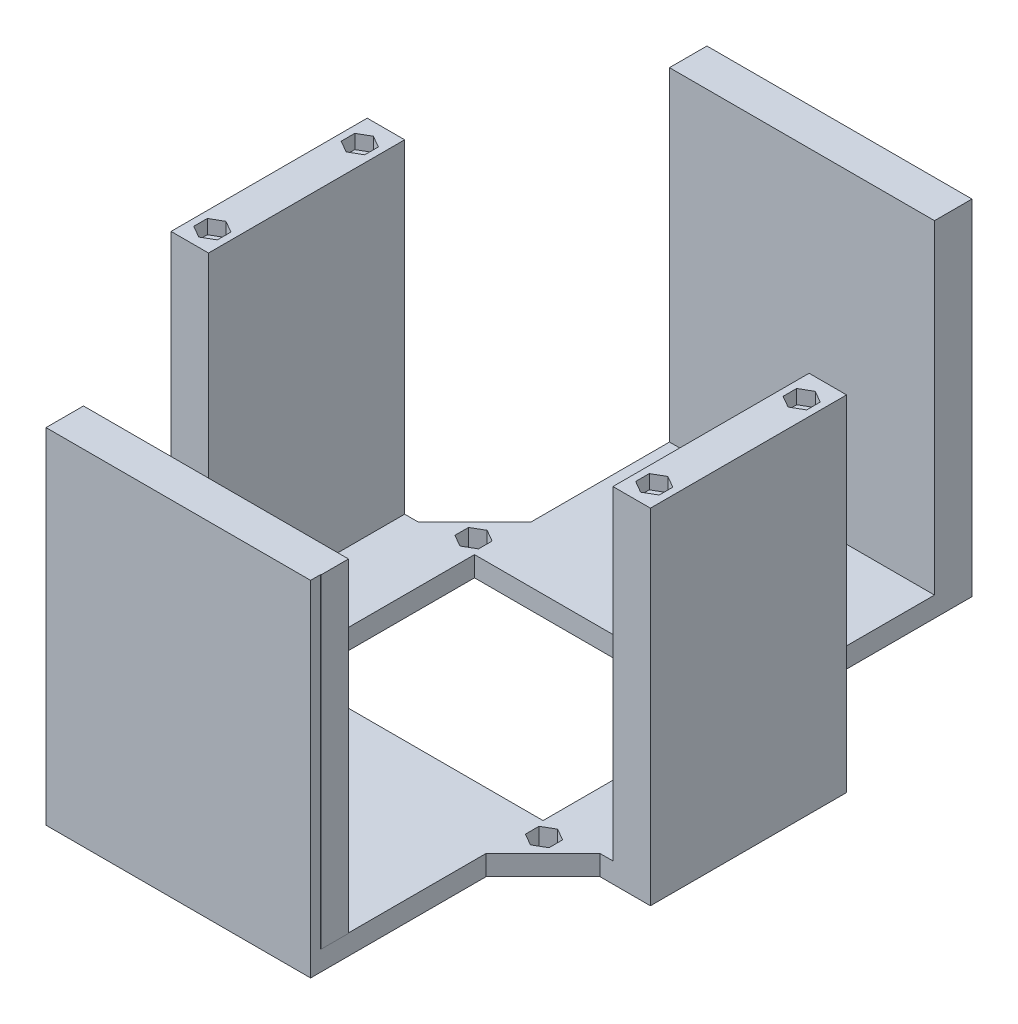
from build123d import *

# Parameters (mm, degrees)
BOSS_EXTRUDE1_DEPTH   = 20
BOSS_EXTRUDE1_2_DEPTH = 20
BOSS_EXTRUDE1_3_DEPTH = 20
BOSS_EXTRUDE1_4_DEPTH = 20
SKETCH6_W             = 12
SKETCH6_H             = 5
BOSS_EXTRUDE5_DEPTH   = 65.8
SKETCH7_W             = 12
SKETCH7_H             = 5
BOSS_EXTRUDE6_DEPTH   = 48.7
SKETCH8_W             = 12.175
SKETCH8_H             = 5
BOSS_EXTRUDE7_DEPTH   = 12.16
SKETCH9_W             = 12.175
SKETCH9_H             = 5
BOSS_EXTRUDE8_DEPTH   = 12.16
SKETCH11_W            = 6.8
SKETCH11_H            = 12.175
BOSS_EXTRUDE9_DEPTH   = 80.5
SKETCH14_W            = 12.175
SKETCH14_H            = 5
BOSS_EXTRUDE12_DEPTH  = 43.2
SKETCH15_W            = 12.175
SKETCH15_H            = 5
BOSS_EXTRUDE13_DEPTH  = 43.2
SKETCH16_W            = 12.175
SKETCH16_H            = 6.8
BOSS_EXTRUDE14_DEPTH  = 80.5
SKETCH17_W            = 16.970562748
SKETCH17_H            = 15
CUT_EXTRUDE1_DEPTH    = 10
SKETCH18_W            = 16.970562748
SKETCH18_H            = 15
CUT_EXTRUDE2_DEPTH    = 10
SKETCH19_W            = 16.970562748
SKETCH19_H            = 15
CUT_EXTRUDE3_DEPTH    = 10
SKETCH20_W            = 16.970562748
SKETCH20_H            = 15
CUT_EXTRUDE4_DEPTH    = 10
BOSS_EXTRUDE15_DEPTH  = 50
BOSS_EXTRUDE16_DEPTH  = 30
SKETCH26_W            = 16.970562748
SKETCH26_H            = 5
BOSS_EXTRUDE17_DEPTH  = 1.5
SKETCH27_W            = 1.5
SKETCH27_H            = 5
BOSS_EXTRUDE18_DEPTH  = 2.5
SKETCH28_W            = 1.5
SKETCH28_H            = 5
BOSS_EXTRUDE20_DEPTH  = 2.5
SKETCH29_W            = 16.810915376
SKETCH29_H            = 5
BOSS_EXTRUDE21_DEPTH  = 1.5
SKETCH30_W            = 1.5
SKETCH30_H            = 5
BOSS_EXTRUDE22_DEPTH  = 3.5
SKETCH31_W            = 1.5
SKETCH31_H            = 5
BOSS_EXTRUDE23_DEPTH  = 3.5
SKETCH32_W            = 16.781669725
SKETCH32_H            = 5
BOSS_EXTRUDE24_DEPTH  = 1.5
SKETCH33_W            = 1.5
SKETCH33_H            = 5
BOSS_EXTRUDE25_DEPTH  = 2.5
SKETCH34_W            = 1.5
SKETCH34_H            = 5
BOSS_EXTRUDE26_DEPTH  = 2.5
SKETCH35_W            = 16.941317097
SKETCH35_H            = 5
BOSS_EXTRUDE27_DEPTH  = 1.5
SKETCH36_W            = 1.5
SKETCH36_H            = 5
BOSS_EXTRUDE28_DEPTH  = 2.5
SKETCH38_W            = 1.5
SKETCH38_H            = 5
BOSS_EXTRUDE29_DEPTH  = 2.5
SKETCH43_W            = 48.7
SKETCH43_H            = 85.5
BOSS_EXTRUDE30_DEPTH  = 2.5
SKETCH44_W            = 48.7
SKETCH44_H            = 85.5
BOSS_EXTRUDE31_DEPTH  = 2.5
SKETCH45_W            = 65.68711226
SKETCH45_H            = 85.5
BOSS_EXTRUDE32_DEPTH  = 2.5
SKETCH46_W            = 65.8
SKETCH46_H            = 85.5
BOSS_EXTRUDE33_DEPTH  = 2.5
CUT_EXTRUDE5_DEPTH    = 3.5


with BuildPart() as part:
    # Sketch2 → Boss-Extrude1 (new body)
    with BuildSketch(Plane(origin=(0, 0, 0), x_dir=(1, 0, 0), z_dir=(0, 1, 0))):
        Polygon((-32.84355613, 36.339660101), (-32.84355613, 24.339660101), (-44.84355613, 24.339660101), align=None)
        Polygon((-33.575, 29.438749537), (-33.575, 26.061250463), (-36.5, 24.372500925), (-39.425, 26.061250463), (-39.425, 29.438749537), (-36.5, 31.127499075), align=None, mode=Mode.SUBTRACT)
    extrude(amount=BOSS_EXTRUDE1_DEPTH)



with BuildPart() as body_2:
    # Sketch2 → Boss-Extrude1 2 (new body)
    with BuildSketch(Plane(origin=(0, 0, 0), x_dir=(1, 0, 0), z_dir=(0, 1, 0))):
        Polygon((32.84355613, 24.339660101), (44.84355613, 24.339660101), (32.84355613, 36.339660101), align=None)
        Polygon((33.575, 29.438749537), (33.575, 26.061250463), (36.5, 24.372500925), (39.425, 26.061250463), (39.425, 29.438749537), (36.5, 31.127499075), align=None, mode=Mode.SUBTRACT)
    extrude(amount=BOSS_EXTRUDE1_2_DEPTH)


with BuildPart() as body_3:
    # Sketch2 → Boss-Extrude1 3 (new body)
    with BuildSketch(Plane(origin=(0, 0, 0), x_dir=(1, 0, 0), z_dir=(0, 1, 0))):
        Polygon((44.84355613, -24.339660101), (32.84355613, -36.339660101), (32.84355613, -24.339660101), align=None)
        Polygon((39.425, -26.061250463), (39.425, -29.438749537), (36.5, -31.127499075), (33.575, -29.438749537), (33.575, -26.061250463), (36.5, -24.372500925), align=None, mode=Mode.SUBTRACT)
    extrude(amount=BOSS_EXTRUDE1_3_DEPTH)


with BuildPart() as body_4:
    # Sketch2 → Boss-Extrude1 4 (new body)
    with BuildSketch(Plane(origin=(0, 0, 0), x_dir=(1, 0, 0), z_dir=(0, 1, 0))):
        Polygon((-44.84355613, -24.339660101), (-32.84355613, -36.339660101), (-32.84355613, -24.339660101), align=None)
        Polygon((-36.5, -31.127499075), (-33.575, -29.438749537), (-33.575, -26.061250463), (-36.5, -24.372500925), (-39.425, -26.061250463), (-39.425, -29.438749537), align=None, mode=Mode.SUBTRACT)
    extrude(amount=BOSS_EXTRUDE1_4_DEPTH)


with BuildPart() as part_1:
    add(part.part)

    add(body_2.part)  # Boss-Extrude5 merges body 2

    add(body_3.part)  # Boss-Extrude5 merges body 3

    add(body_4.part)  # Boss-Extrude5 merges body 4
    # Sketch6 → Boss-Extrude5 (add)
    with BuildSketch(Plane(origin=(-32.84355613, 0, 0), x_dir=(0, 0, -1), z_dir=(1, 0, 0))):
        with Locations((30.339660101, 17.5)):
            Rectangle(SKETCH6_W, SKETCH6_H)
        with Locations((-30.339660101, 17.5)):
            Rectangle(SKETCH6_W, SKETCH6_H)
    extrude(amount=BOSS_EXTRUDE5_DEPTH)

    # Sketch7 → Boss-Extrude6 (add)
    with BuildSketch(Plane(origin=(0, 0, 24.339660101), x_dir=(-1, 0, 0), z_dir=(0, 0, -1))):
        with Locations((-38.84355613, 17.5)):
            Rectangle(SKETCH7_W, SKETCH7_H)
        with Locations((38.84355613, 17.5)):
            Rectangle(SKETCH7_W, SKETCH7_H)
    extrude(amount=BOSS_EXTRUDE6_DEPTH)

    # Sketch8 → Boss-Extrude7 (add)
    with BuildSketch(Plane(origin=(44.84355613, 0, 0), x_dir=(0, 0, -1), z_dir=(1, 0, 0))):
        with Locations((-18.252160101, 17.5)):
            Rectangle(SKETCH8_W, SKETCH8_H)
        with Locations((18.272839899, 17.5)):
            Rectangle(SKETCH8_W, SKETCH8_H)
    extrude(amount=BOSS_EXTRUDE7_DEPTH)

    # Sketch9 → Boss-Extrude8 (add)
    with BuildSketch(Plane.ZY.offset(44.84355613)):
        with Locations((-18.272839899, 17.5)):
            Rectangle(SKETCH9_W, SKETCH9_H)
        with Locations((18.252160101, 17.5)):
            Rectangle(SKETCH9_W, SKETCH9_H)
    extrude(amount=BOSS_EXTRUDE8_DEPTH)

    # Sketch11 → Boss-Extrude9 (add)
    with BuildSketch(Plane(origin=(0, 20, 0), x_dir=(1, 0, 0), z_dir=(0, 1, 0))):
        with Locations((-53.60355613, -18.252160101)):
            Rectangle(SKETCH11_W, SKETCH11_H)
        with Locations((-53.60355613, 18.272839899)):
            Rectangle(SKETCH11_W, SKETCH11_H)
        with Locations((53.60355613, 18.272839899)):
            Rectangle(SKETCH11_W, SKETCH11_H)
        with Locations((53.60355613, -18.252160101)):
            Rectangle(SKETCH11_W, SKETCH11_H)
    extrude(amount=BOSS_EXTRUDE9_DEPTH)

    # Sketch14 → Boss-Extrude12 (add)
    with BuildSketch(Plane.XY.offset(36.339660101)):
        with Locations((-26.75605613, 17.5)):
            Rectangle(SKETCH14_W, SKETCH14_H)
        with Locations((26.75605613, 17.5)):
            Rectangle(SKETCH14_W, SKETCH14_H)
    extrude(amount=BOSS_EXTRUDE12_DEPTH)

    # Sketch15 → Boss-Extrude13 (add)
    with BuildSketch(Plane(origin=(0, 0, -36.339660101), x_dir=(-1, 0, 0), z_dir=(0, 0, -1))):
        with Locations((-26.86894387, 17.5)):
            Rectangle(SKETCH15_W, SKETCH15_H)
        with Locations((26.75605613, 17.5)):
            Rectangle(SKETCH15_W, SKETCH15_H)
    extrude(amount=BOSS_EXTRUDE13_DEPTH)

    # Sketch16 → Boss-Extrude14 (add)
    with BuildSketch(Plane(origin=(0, 20, 0), x_dir=(1, 0, 0), z_dir=(0, 1, 0))):
        with Locations((-26.75605613, 76.139660101)):
            Rectangle(SKETCH16_W, SKETCH16_H)
        with Locations((26.86894387, 76.139660101)):
            Rectangle(SKETCH16_W, SKETCH16_H)
        with Locations((26.86894387, -76.139660101)):
            Rectangle(SKETCH16_W, SKETCH16_H)
        with Locations((-26.75605613, -76.139660101)):
            Rectangle(SKETCH16_W, SKETCH16_H)
    extrude(amount=BOSS_EXTRUDE14_DEPTH)

    # Sketch17 → Cut-Extrude1 (cut)
    with BuildSketch(Plane(origin=(34.591608116, 0, -34.591608116), x_dir=(-0.707106781, 0, -0.707106781), z_dir=(0.707106781, 0, -0.707106781))):
        with Locations((-6.013162549, 7.5)):
            Rectangle(SKETCH17_W, SKETCH17_H)
    extrude(amount=-CUT_EXTRUDE1_DEPTH, mode=Mode.SUBTRACT)

    # Sketch18 → Cut-Extrude2 (cut)
    with BuildSketch(Plane(origin=(-34.591608116, 0, -34.591608116), x_dir=(-0.707106781, 0, 0.707106781), z_dir=(-0.707106781, 0, -0.707106781))):
        with Locations((6.013162549, 7.5)):
            Rectangle(SKETCH18_W, SKETCH18_H)
    extrude(amount=-CUT_EXTRUDE2_DEPTH, mode=Mode.SUBTRACT)

    # Sketch19 → Cut-Extrude3 (cut)
    with BuildSketch(Plane(origin=(-34.591608116, 0, 34.591608116), x_dir=(0.707106781, 0, 0.707106781), z_dir=(-0.707106781, 0, 0.707106781))):
        with Locations((-6.013162549, 7.5)):
            Rectangle(SKETCH19_W, SKETCH19_H)
    extrude(amount=-CUT_EXTRUDE3_DEPTH, mode=Mode.SUBTRACT)

    # Sketch20 → Cut-Extrude4 (cut)
    with BuildSketch(Plane(origin=(34.591608116, 0, 34.591608116), x_dir=(0.707106781, 0, -0.707106781), z_dir=(0.707106781, 0, 0.707106781))):
        with Locations((6.013162549, 7.5)):
            Rectangle(SKETCH20_W, SKETCH20_H)
    extrude(amount=-CUT_EXTRUDE4_DEPTH, mode=Mode.SUBTRACT)

    # Sketch21 → Boss-Extrude15 (add)
    with BuildSketch(Plane(origin=(-20.66855613, 0, 0), x_dir=(0, 0, -1), z_dir=(1, 0, 0))):
        Polygon((-79.539660101, 100.5), (-72.739660101, 100.5), (-72.739660101, 20), (-36.339660101, 20), (-36.339660101, 15), (-79.539660101, 15), align=None)
        Polygon((79.539660101, 100.5), (72.739660101, 100.5), (72.739660101, 20), (36.339660101, 20), (36.339660101, 15), (79.539660101, 15), align=None)
    extrude(amount=BOSS_EXTRUDE15_DEPTH)

    # Sketch25 → Boss-Extrude16 (add)
    with BuildSketch(Plane.XY.offset(-12.185339899)):
        Polygon((-50.20355613, 100.5), (-57.00355613, 100.5), (-57.00355613, 15), (-44.84355613, 15), (-44.84355613, 20), (-50.20355613, 20), align=None)
        Polygon((50.20355613, 100.5), (57.00355613, 100.5), (57.00355613, 15), (44.84355613, 15), (44.84355613, 20), (50.20355613, 20), align=None)
    extrude(amount=BOSS_EXTRUDE16_DEPTH)

    # Sketch26 → Boss-Extrude17 (add)
    with BuildSketch(Plane(origin=(-34.591608116, 0, 34.591608116), x_dir=(0.707106781, 0, 0.707106781), z_dir=(-0.707106781, 0, 0.707106781))):
        with Locations((-6.013162549, 17.5)):
            Rectangle(SKETCH26_W, SKETCH26_H)
    extrude(amount=BOSS_EXTRUDE17_DEPTH)

    # Sketch27 → Boss-Extrude18 (add)
    with BuildSketch(Plane(origin=(1.748051985, 0, 1.748051985), x_dir=(0.707106781, 0, -0.707106781), z_dir=(0.707106781, 0, 0.707106781))):
        with Locations((-49.669921341, 17.5)):
            Rectangle(SKETCH27_W, SKETCH27_H)
    extrude(amount=BOSS_EXTRUDE18_DEPTH)

    # Sketch28 → Boss-Extrude20 (add)
    with BuildSketch(Plane(origin=(-10.251948015, 0, -10.251948015), x_dir=(-0.707106781, 0, 0.707106781), z_dir=(-0.707106781, 0, -0.707106781))):
        with Locations((49.669921341, 17.5)):
            Rectangle(SKETCH28_W, SKETCH28_H)
    extrude(amount=BOSS_EXTRUDE20_DEPTH)

    # Sketch29 → Boss-Extrude21 (add)
    with BuildSketch(Plane(origin=(34.591608116, 0, 34.591608116), x_dir=(0.707106781, 0, -0.707106781), z_dir=(0.707106781, 0, 0.707106781))):
        with Locations((6.092986235, 17.5)):
            Rectangle(SKETCH29_W, SKETCH29_H)
    extrude(amount=BOSS_EXTRUDE21_DEPTH)

    # Sketch30 → Boss-Extrude22 (add)
    with BuildSketch(Plane(origin=(-1.635164246, 0, 1.635164246), x_dir=(0.707106781, 0, 0.707106781), z_dir=(-0.707106781, 0, 0.707106781))):
        with Locations((49.669921341, 17.5)):
            Rectangle(SKETCH30_W, SKETCH30_H)
    extrude(amount=BOSS_EXTRUDE22_DEPTH)

    # Sketch31 → Boss-Extrude23 (add)
    with BuildSketch(Plane(origin=(10.251948015, 0, -10.251948015), x_dir=(-0.707106781, 0, -0.707106781), z_dir=(0.707106781, 0, -0.707106781))):
        with Locations((-49.669921341, 17.5)):
            Rectangle(SKETCH31_W, SKETCH31_H)
    extrude(amount=BOSS_EXTRUDE23_DEPTH)

    # Sketch32 → Boss-Extrude24 (add)
    with BuildSketch(Plane(origin=(34.591608116, 0, -34.591608116), x_dir=(-0.707106781, 0, -0.707106781), z_dir=(0.707106781, 0, -0.707106781))):
        with Locations((-6.07836341, 17.5)):
            Rectangle(SKETCH32_W, SKETCH32_H)
    extrude(amount=BOSS_EXTRUDE24_DEPTH)

    # Sketch33 → Boss-Extrude25 (add)
    with BuildSketch(Plane(origin=(10.231268217, 0, 10.231268217), x_dir=(0.707106781, 0, -0.707106781), z_dir=(0.707106781, 0, 0.707106781))):
        with Locations((49.669921341, 17.5)):
            Rectangle(SKETCH33_W, SKETCH33_H)
    extrude(amount=BOSS_EXTRUDE25_DEPTH)

    # Sketch34 → Boss-Extrude26 (add)
    with BuildSketch(Plane(origin=(-1.635164246, 0, -1.635164246), x_dir=(-0.707106781, 0, 0.707106781), z_dir=(-0.707106781, 0, -0.707106781))):
        with Locations((-49.669921341, 17.5)):
            Rectangle(SKETCH34_W, SKETCH34_H)
    extrude(amount=BOSS_EXTRUDE26_DEPTH)

    # Sketch35 → Boss-Extrude27 (add)
    with BuildSketch(Plane(origin=(-34.591608116, 0, -34.591608116), x_dir=(-0.707106781, 0, 0.707106781), z_dir=(-0.707106781, 0, -0.707106781))):
        with Locations((5.998539724, 17.5)):
            Rectangle(SKETCH35_W, SKETCH35_H)
    extrude(amount=BOSS_EXTRUDE27_DEPTH)

    # Sketch36 → Boss-Extrude28 (add)
    with BuildSketch(Plane(origin=(1.748051985, 0, -1.748051985), x_dir=(-0.707106781, 0, -0.707106781), z_dir=(0.707106781, 0, -0.707106781))):
        with Locations((49.669921341, 17.5)):
            Rectangle(SKETCH36_W, SKETCH36_H)
    extrude(amount=BOSS_EXTRUDE28_DEPTH)

    # Sketch38 → Boss-Extrude29 (add)
    with BuildSketch(Plane(origin=(-10.231268217, 0, 10.231268217), x_dir=(0.707106781, 0, 0.707106781), z_dir=(-0.707106781, 0, 0.707106781))):
        with Locations((-49.669921341, 17.5)):
            Rectangle(SKETCH38_W, SKETCH38_H)
    extrude(amount=BOSS_EXTRUDE29_DEPTH)

    # Sketch43 → Boss-Extrude30 (add)
    with BuildSketch(Plane.ZY.offset(57.00355613)):
        with Locations((-0.010339899, 57.75)):
            Rectangle(SKETCH43_W, SKETCH43_H)
    extrude(amount=BOSS_EXTRUDE30_DEPTH)

    # Sketch44 → Boss-Extrude31 (add)
    with BuildSketch(Plane(origin=(57.00355613, 0, 0), x_dir=(0, 0, -1), z_dir=(1, 0, 0))):
        with Locations((0.010339899, 57.75)):
            Rectangle(SKETCH44_W, SKETCH44_H)
    extrude(amount=BOSS_EXTRUDE31_DEPTH)

    # Sketch45 → Boss-Extrude32 (add)
    with BuildSketch(Plane.XY.offset(79.539660101)):
        with Locations((0, 57.75)):
            Rectangle(SKETCH45_W, SKETCH45_H)
    extrude(amount=BOSS_EXTRUDE32_DEPTH)

    # Sketch46 → Boss-Extrude33 (add)
    with BuildSketch(Plane(origin=(0, 0, -79.539660101), x_dir=(-1, 0, 0), z_dir=(0, 0, -1))):
        with Locations((-0.05644387, 57.75)):
            Rectangle(SKETCH46_W, SKETCH46_H)
    extrude(amount=BOSS_EXTRUDE33_DEPTH)

    # Sketch47 → Cut-Extrude5 (cut)
    with BuildSketch(Plane(origin=(0, 100.5, 0), x_dir=(1, 0, 0), z_dir=(0, 1, 0))):
        Polygon((-54.85355613, -22.116831472), (-51.92855613, -20.428081935), (-51.92855613, -17.05058286), (-54.85355613, -15.361833323), (-57.77855613, -17.05058286), (-57.77855613, -20.428081935), align=None)
        Polygon((57.77855613, 16.171590362), (54.85355613, 14.482840824), (51.92855613, 16.171590362), (51.92855613, 19.549089436), (54.85355613, 21.237838974), (57.77855613, 19.549089436), align=None)
        Polygon((-54.85355613, 14.482840824), (-51.92855613, 16.171590362), (-51.92855613, 19.549089436), (-54.85355613, 21.237838974), (-57.77855613, 19.549089436), (-57.77855613, 16.171590362), align=None)
        Polygon((57.77855613, -20.428081935), (54.85355613, -22.116831472), (51.92855613, -20.428081935), (51.92855613, -17.05058286), (54.85355613, -15.361833323), (57.77855613, -17.05058286), align=None)
    extrude(amount=-CUT_EXTRUDE5_DEPTH, mode=Mode.SUBTRACT)


solid = part_1.part
